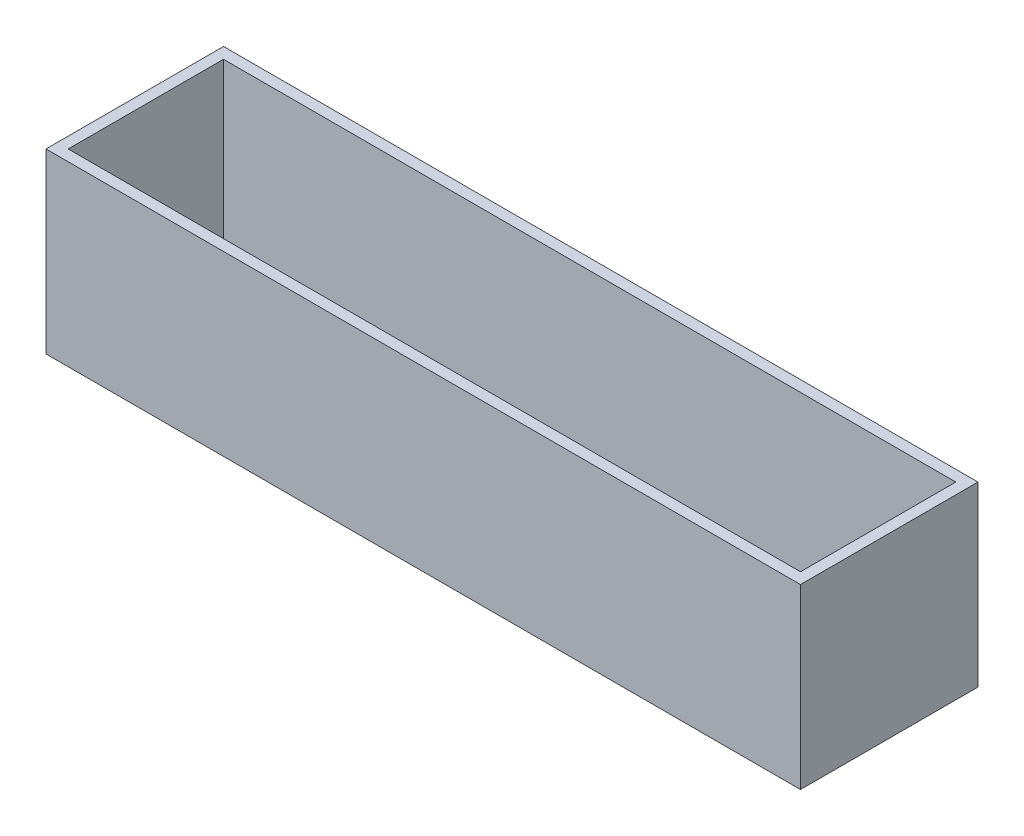
from build123d import *

# Parameters (mm, degrees)
CROQUIS1_W              = 170
CROQUIS1_H              = 40
SALIENTE_EXTRUIR1_DEPTH = 40
CROQUIS2_W              = 165
CROQUIS2_H              = 35
CORTAR_EXTRUIR1_DEPTH   = 37.5


with BuildPart() as part:
    # Croquis1 → Saliente-Extruir1 (new body)
    with BuildSketch(Plane(origin=(0, 0, 0), x_dir=(1, 0, 0), z_dir=(0, 1, 0))):
        with Locations((3.426966292, 0.561797753)):
            Rectangle(CROQUIS1_W, CROQUIS1_H)
    extrude(amount=SALIENTE_EXTRUIR1_DEPTH)

    # Croquis2 → Cortar-Extruir1 (cut)
    with BuildSketch(Plane(origin=(0, 40, 0), x_dir=(1, 0, 0), z_dir=(0, 1, 0))):
        with Locations((3.426966292, 0.561797753)):
            Rectangle(CROQUIS2_W, CROQUIS2_H)
    extrude(amount=-CORTAR_EXTRUIR1_DEPTH, mode=Mode.SUBTRACT)


solid = part.part
